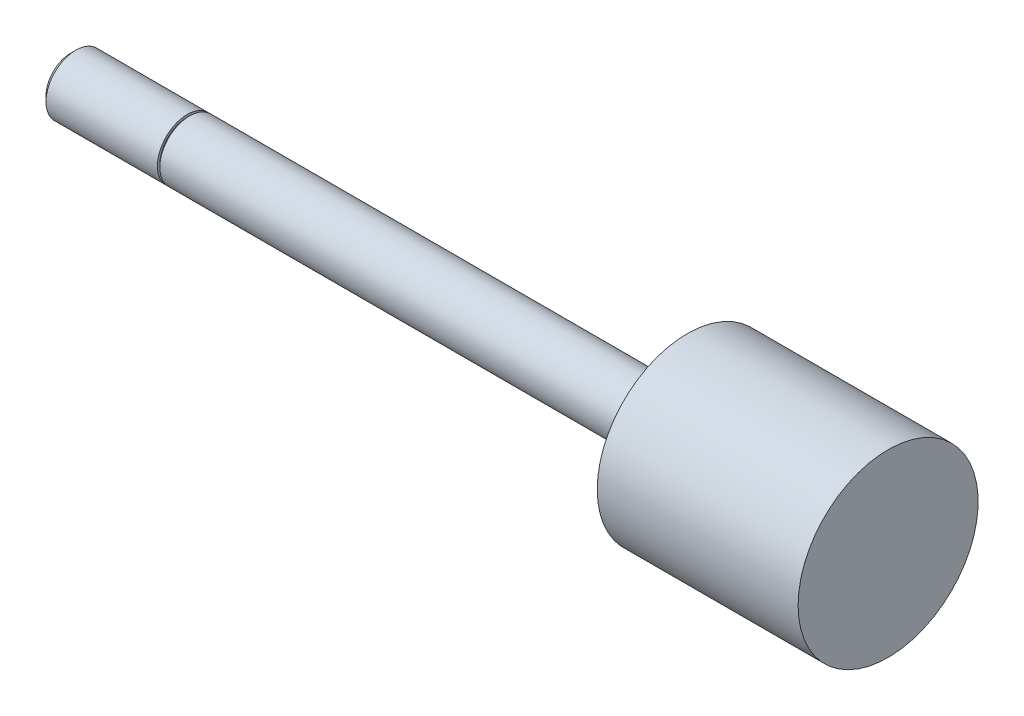
from build123d import *

# Parameters (mm, degrees)
SKETCH3_W = 0.254
SKETCH3_H = 0.508


with BuildPart() as part:
    # Sketch1 → Revolve1 (revolve)
    with BuildSketch(Plane.XY):
        Polygon((0, 0), (0, 3.175), (53.1876, 3.175), (53.1876, 9.62025), (74.6506, 9.62025), (74.6506, 0), align=None)
    revolve(axis=Axis((74.6506, 0, 0), (-1, 0, 0)))

    # Sketch2 → Revolve2 (revolve)
    with BuildSketch(Plane.XY):
        Polygon((-12.7, 0), (-12.7, 2.63398), (-12.15898, 3.175), (0, 3.175), (0, 0), align=None)
    revolve(axis=Axis((0, 0, 0), (-1, 0, 0)))

    # Sketch3 → Cut-Revolve1 (revolve, cut)
    with BuildSketch(Plane.XY):
        with Locations((-0.127, 3.175)):
            Rectangle(SKETCH3_W, SKETCH3_H)
    revolve(axis=Axis((0, 0, 0), (-1, 0, 0)), mode=Mode.SUBTRACT)


solid = part.part
